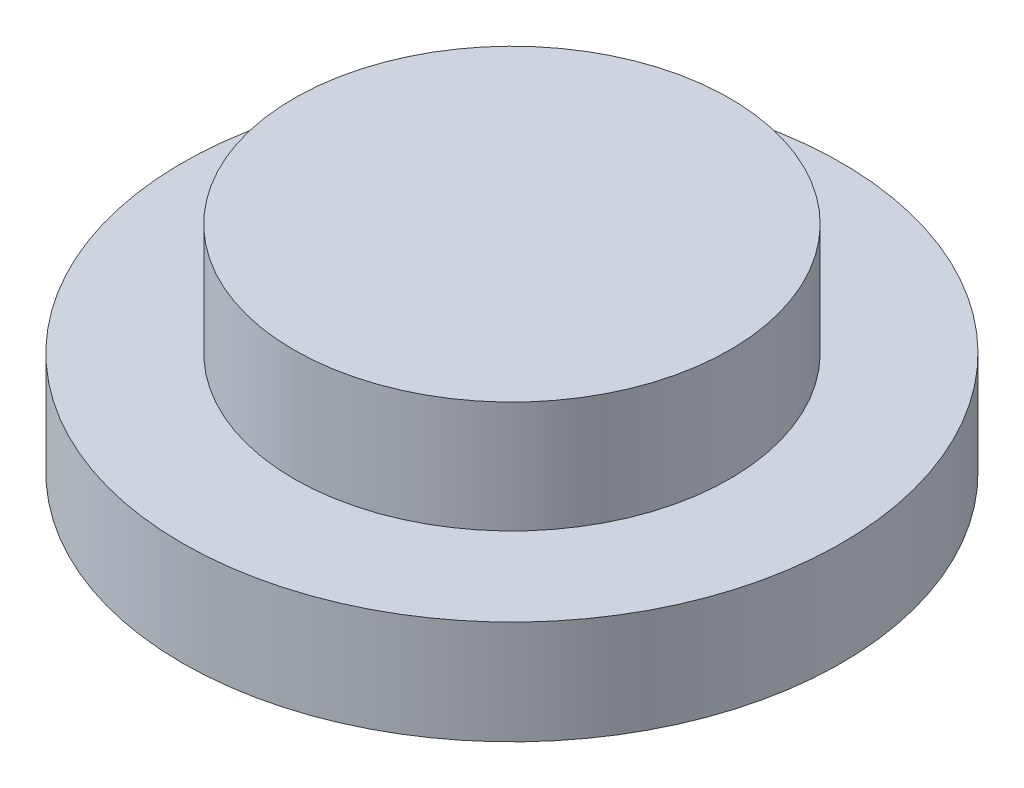
from build123d import *

# Parameters (mm, degrees)
SKETCH1_R           = 9.525
BOSS_EXTRUDE1_DEPTH = 2.9972
SKETCH2_R           = 6.2992
BOSS_EXTRUDE2_DEPTH = 3.2258


with BuildPart() as part:
    # Sketch1 → Boss-Extrude1 (new body)
    with BuildSketch(Plane(origin=(0, 0, 0), x_dir=(1, 0, 0), z_dir=(0, 1, 0))):
        Circle(SKETCH1_R)
    extrude(amount=BOSS_EXTRUDE1_DEPTH)

    # Sketch2 → Boss-Extrude2 (add)
    with BuildSketch(Plane(origin=(0, 2.9972, 0), x_dir=(1, 0, 0), z_dir=(0, 1, 0))):
        Circle(SKETCH2_R)
    extrude(amount=BOSS_EXTRUDE2_DEPTH)


solid = part.part
